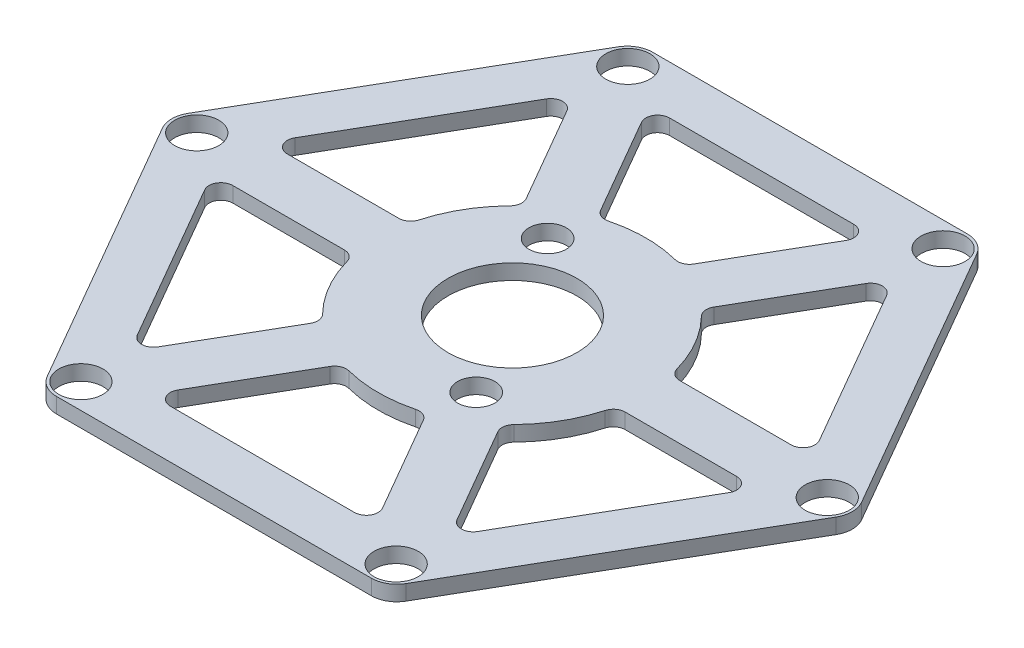
from build123d import *

# Parameters (mm, degrees)
SKETCH1_R           = 2.6
SKETCH1_R_2         = 2.2
SKETCH1_R_3         = 7.6
BOSS_EXTRUDE1_DEPTH = 1.8
FILLET1_R           = 3
FILLET2_R           = 1.4
SCALE1_SCALE        = 1.15


with BuildPart() as part:
    # Sketch1 → Boss-Extrude1 (new body)
    with BuildSketch(Plane(origin=(0, 0, 0), x_dir=(1, 0, 0), z_dir=(0, 1, 0))):
        Polygon((20.3, 35.160631394), (-20.3, 35.160631394), (-40.6, 0), (-20.3, -35.160631394), (20.3, -35.160631394), (40.6, 0), align=None)
        with Locations((-18.636201283, -32.21652123)):
            Circle(SKETCH1_R, mode=Mode.SUBTRACT)
        with Locations((18.582225165, -32.247684356)):
            Circle(SKETCH1_R, mode=Mode.SUBTRACT)
        with Locations((37.218426448, -0.031163126)):
            Circle(SKETCH1_R, mode=Mode.SUBTRACT)
        with Locations((-37.218426448, 0.031163126)):
            Circle(SKETCH1_R, mode=Mode.SUBTRACT)
        with BuildLine():
            Line((-32.142053523, 3.218057696), (-18.857946477, 26.226806032))
            Line((-18.857946477, 26.226806032), (-10.521325069, 11.78735419))
            ThreePointArc((-10.521325069, 11.78735419), (-13.68320138, 7.9), (-15.468810706, 3.218057696))
            Line((-15.468810706, 3.218057696), (-32.142053523, 3.218057696))
        make_face(mode=Mode.SUBTRACT)
        with BuildLine():
            Line((-18.857946477, -26.226806032), (-32.142053523, -3.218057696))
            Line((-32.142053523, -3.218057696), (-15.468810706, -3.218057696))
            ThreePointArc((-15.468810706, -3.218057696), (-13.68320138, -7.9), (-10.521325069, -11.78735419))
            Line((-10.521325069, -11.78735419), (-18.857946477, -26.226806032))
        make_face(mode=Mode.SUBTRACT)
        with BuildLine():
            Line((13.284107046, -29.444863729), (-13.284107046, -29.444863729))
            Line((-13.284107046, -29.444863729), (-4.947485637, -15.005411886))
            ThreePointArc((-4.947485637, -15.005411886), (0, -15.8), (4.947485637, -15.005411886))
            Line((4.947485637, -15.005411886), (13.284107046, -29.444863729))
        make_face(mode=Mode.SUBTRACT)
        with BuildLine():
            Line((32.142053523, -3.218057696), (18.857946477, -26.226806032))
            Line((18.857946477, -26.226806032), (10.521325069, -11.78735419))
            ThreePointArc((10.521325069, -11.78735419), (13.68320138, -7.9), (15.468810706, -3.218057696))
            Line((15.468810706, -3.218057696), (32.142053523, -3.218057696))
        make_face(mode=Mode.SUBTRACT)
        with BuildLine():
            Line((18.857946477, 26.226806032), (32.142053523, 3.218057696))
            Line((32.142053523, 3.218057696), (15.468810706, 3.218057696))
            ThreePointArc((15.468810706, 3.218057696), (13.68320138, 7.9), (10.521325069, 11.78735419))
            Line((10.521325069, 11.78735419), (18.857946477, 26.226806032))
        make_face(mode=Mode.SUBTRACT)
        with BuildLine():
            Line((-13.284107046, 29.444863729), (13.284107046, 29.444863729))
            Line((13.284107046, 29.444863729), (4.947485637, 15.005411886))
            ThreePointArc((4.947485637, 15.005411886), (0, 15.8), (-4.947485637, 15.005411886))
            Line((-4.947485637, 15.005411886), (-13.284107046, 29.444863729))
        make_face(mode=Mode.SUBTRACT)
        with Locations((-18.582225165, 32.247684356)):
            Circle(SKETCH1_R, mode=Mode.SUBTRACT)
        with Locations((18.636201283, 32.21652123)):
            Circle(SKETCH1_R, mode=Mode.SUBTRACT)
        with Locations((5.763168727, -9.982101048)):
            Circle(SKETCH1_R_2, mode=Mode.SUBTRACT)
        with Locations((-5.736740168, 9.936325441)):
            Circle(SKETCH1_R_2, mode=Mode.SUBTRACT)
        with Locations((0.052857117, 0)):
            Circle(SKETCH1_R_3, mode=Mode.SUBTRACT)
    extrude(amount=BOSS_EXTRUDE1_DEPTH)

    # Fillet1
    fillet1_edges = [part.edges().sort_by_distance(p)[0] for p in [
        (40.6, 0.9, 0),
        (20.3, 0.9, 35.160631394),
        (-20.3, 0.9, 35.160631394),
        (-40.6, 0.9, 0),
        (-20.3, 0.9, -35.160631394),
        (20.3, 0.9, -35.160631394),
    ]]
    fillet(fillet1_edges, radius=FILLET1_R)

    # Fillet2
    fillet2_edges = [part.edges().sort_by_distance(p)[0] for p in [
        (-32.142053523, 0.9, -3.218057696),
        (-15.468810706, 0.9, -3.218057696),
        (-10.521325069, 0.9, -11.78735419),
        (-18.857946477, 0.9, -26.226806032),
        (-18.857946477, 0.9, 26.226806032),
        (-10.521325069, 0.9, 11.78735419),
        (-15.468810706, 0.9, 3.218057696),
        (-32.142053523, 0.9, 3.218057696),
        (13.284107046, 0.9, 29.444863729),
        (4.947485637, 0.9, 15.005411886),
        (-4.947485637, 0.9, 15.005411886),
        (-13.284107046, 0.9, 29.444863729),
        (32.142053523, 0.9, 3.218057696),
        (15.468810706, 0.9, 3.218057696),
        (10.521325069, 0.9, 11.78735419),
        (18.857946477, 0.9, 26.226806032),
        (18.857946477, 0.9, -26.226806032),
        (10.521325069, 0.9, -11.78735419),
        (15.468810706, 0.9, -3.218057696),
        (32.142053523, 0.9, -3.218057696),
        (-13.284107046, 0.9, -29.444863729),
        (-4.947485637, 0.9, -15.005411886),
        (4.947485637, 0.9, -15.005411886),
        (13.284107046, 0.9, -29.444863729),
    ]]
    fillet(fillet2_edges, radius=FILLET2_R)


with BuildPart() as part_1:
    # Scale1: scaled about (-0.004144331, 0.9, -0.000288654)
    add(part.part.scale(SCALE1_SCALE).moved(Location((0.00062165, -0.135, 4.3298e-05))))


solid = part_1.part
